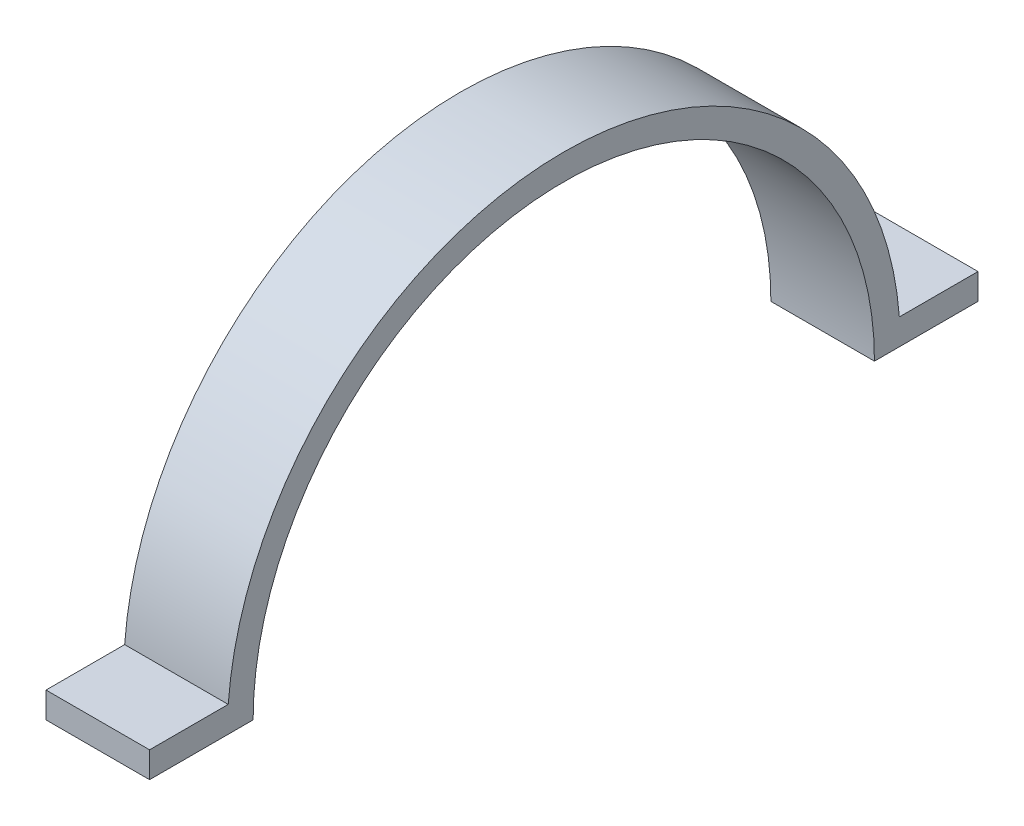
from build123d import *

# Parameters (mm, degrees)
BOSS_EXTRUDE1_DEPTH = 10


with BuildPart() as part:
    # Sketch1 → Boss-Extrude1 (new body)
    with BuildSketch(Plane(origin=(0, 0, 0), x_dir=(0, 0, -1), z_dir=(1, 0, 0))):
        with BuildLine():
            Line((-30, 0), (-40, 0))
            Line((-40, 0), (-40, 2.5))
            Line((-40, 2.5), (-32.403703492, 2.5))
            ThreePointArc((-32.403703492, 2.5), (0, 32.5), (32.403703492, 2.5))
            Line((32.403703492, 2.5), (40, 2.5))
            Line((40, 2.5), (40, 0))
            Line((40, 0), (30, 0))
            ThreePointArc((30, 0), (0, 30), (-30, 0))
        make_face()
    extrude(amount=BOSS_EXTRUDE1_DEPTH)


solid = part.part
